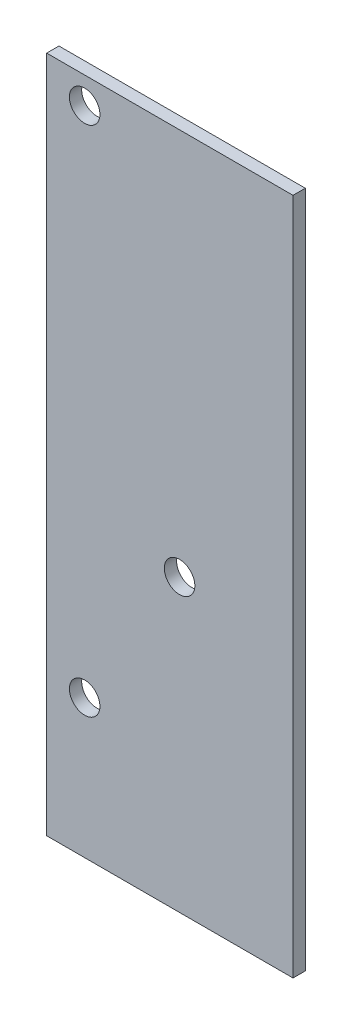
from build123d import *

# Parameters (mm, degrees)
SKETCH1_W              = 41.1988
SKETCH1_H              = 113.3602
BOSS_EXTRUDE1_DEPTH    = 2.05486
F_10_CLEARANCE_HOLE1_D = 5.1054


with BuildPart() as part:
    # Sketch1 → Boss-Extrude1 (new body)
    with BuildSketch(Plane.XY):
        Rectangle(SKETCH1_W, SKETCH1_H)
    extrude(amount=BOSS_EXTRUDE1_DEPTH)

    # #10 Clearance Hole1 (through all)
    with Locations(Plane.XY.offset(2.05486)):
        with Locations((-14.2494, 52.2351), (1.6256, -8.0899), (-14.2494, -33.4899)):
            Hole(F_10_CLEARANCE_HOLE1_D / 2)


solid = part.part
